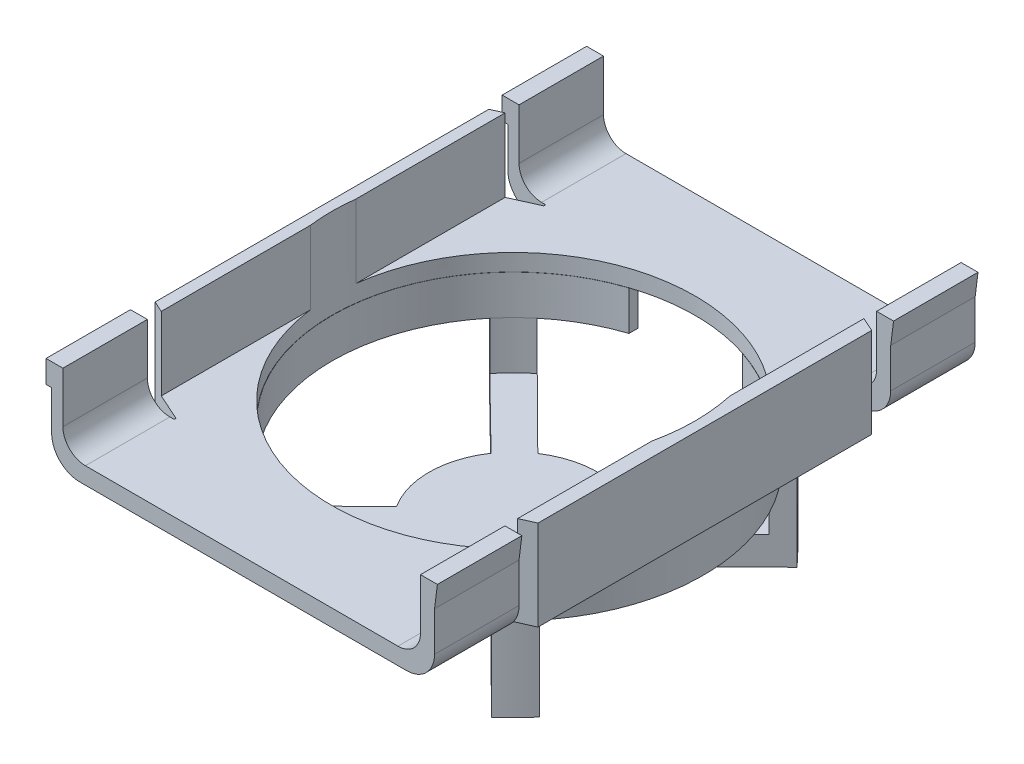
from build123d import *

# Parameters (mm, degrees)
BOSS_EXTRUDE1_DEPTH      = 15
BOSS_EXTRUDE2_DEPTH      = 66
CUT_EXTRUDE1_DEPTH       = 16
FILLET1_R                = 0.2
SKETCH5_R                = 32.25
CUT_EXTRUDE2_DEPTH       = 66
BOSS_EXTRUDE7_DEPTH      = 7
BOSS_EXTRUDE9_DEPTH      = 13.5
BOSS_EXTRUDE9_DEPTH_BACK = 7
BOSS_EXTRUDE10_DEPTH     = 5


with BuildPart() as part:
    # Sketch1 → Boss-Extrude1 (new body)
    with BuildSketch(Plane.XY):
        with BuildLine():
            Line((-35.569135578, 10.252622841), (-35.569135578, 6.252622841))
            Line((-35.569135578, 6.252622841), (-34.569135578, 6.252622841))
            Line((-34.569135578, 6.252622841), (-34.569135578, -0.747377159))
            ThreePointArc((-34.569135578, -0.747377159), (-33.104669484, -4.282911065), (-29.569135578, -5.747377159))
            Line((-29.569135578, -5.747377159), (28.430864422, -5.747377159))
            ThreePointArc((28.430864422, -5.747377159), (31.966398327, -4.282911065), (33.430864422, -0.747377159))
            Line((33.430864422, -0.747377159), (33.430864422, 6.252622841))
            Line((33.430864422, 6.252622841), (33.930864422, 10.252622841))
            Line((33.930864422, 10.252622841), (30.930864422, 10.252622841))
            Line((30.930864422, 10.252622841), (30.930864422, 1.252622841))
            ThreePointArc((30.930864422, 1.252622841), (29.759291546, -1.575804284), (26.930864422, -2.747377159))
            Line((26.930864422, -2.747377159), (-28.569135578, -2.747377159))
            ThreePointArc((-28.569135578, -2.747377159), (-31.397562703, -1.575804284), (-32.569135578, 1.252622841))
            Line((-32.569135578, 1.252622841), (-32.569135578, 10.252622841))
            Line((-32.569135578, 10.252622841), (-35.569135578, 10.252622841))
        make_face()
    boss_extrude1 = extrude(amount=BOSS_EXTRUDE1_DEPTH)

    # Sketch2 → Boss-Extrude2 (add)
    with BuildSketch(Plane.XY.offset(15)):
        Polygon((33.430864422, -5.747377159), (-34.569135578, -5.747377159), (-34.569135578, 10.252622841), (-32.569135578, 10.252622841), (-32.569135578, -2.747377159), (30.930864422, -2.747377159), (30.930864422, 10.252622841), (33.430864422, 10.252622841), align=None)
    extrude(amount=BOSS_EXTRUDE2_DEPTH)

    # Mirror1: Boss-Extrude1 across plane
    add(boss_extrude1.mirror(Plane(origin=(0, 0, 48), x_dir=(1, 0, 0), z_dir=(0, 0, -1))))

    # Sketch4 → Cut-Extrude1 (cut)
    with BuildSketch(Plane.XZ.offset(5.747377159)):
        Polygon((-34.569135578, 15), (-27.069135578, 15), (-34.569135578, 18.37), align=None)
        Polygon((33.430864422, 18.37), (33.430864422, 15), (25.930864422, 15), align=None)
        Polygon((33.430864422, 81), (25.930864422, 81), (33.430864422, 77.63), align=None)
        Polygon((-34.569135578, 77.63), (-34.569135578, 81), (-27.069135578, 81), align=None)
    extrude(amount=-CUT_EXTRUDE1_DEPTH, mode=Mode.SUBTRACT)

    # Fillet1
    fillet1_edges = [part.edges().sort_by_distance(p)[0] for p in [
        (-27.069135578, -4.247377159, 15),
        (25.930864422, -4.247377159, 15),
        (25.930864422, -4.247377159, 81),
        (-27.069135578, -4.247377159, 81),
    ]]
    fillet(fillet1_edges, radius=FILLET1_R)

    # Sketch5 → Cut-Extrude2 (cut)
    with BuildSketch(Plane.XZ.offset(5.747377159)):
        with Locations((-0.569135578, 48)):
            Circle(SKETCH5_R)
    extrude(amount=-CUT_EXTRUDE2_DEPTH, mode=Mode.SUBTRACT)

    # Sketch14 → Boss-Extrude7 (add)
    with BuildSketch(Plane.XZ.offset(5.747377159)):
        with BuildLine():
            Line((-10.647665103, 80.175600928), (-10.647665103, 78.600128297))
            ThreePointArc((-10.647665103, 78.600128297), (-32.786283329, 48), (-10.647665103, 17.399871703))
            Line((-10.647665103, 17.399871703), (-10.647665103, 15.824399072))
            ThreePointArc((-10.647665103, 15.824399072), (-34.286283329, 48), (-10.647665103, 80.175600928))
        make_face()
        with BuildLine():
            Line((9.509393946, 17.399871703), (9.509393946, 15.824399072))
            ThreePointArc((9.509393946, 15.824399072), (33.148012172, 48), (9.509393946, 80.175600928))
            Line((9.509393946, 80.175600928), (9.509393946, 78.600128297))
            ThreePointArc((9.509393946, 78.600128297), (31.648012172, 48), (9.509393946, 17.399871703))
        make_face()
    extrude(amount=BOSS_EXTRUDE7_DEPTH)

    # Sketch15 → Boss-Extrude9 (add, two sides)
    with BuildSketch(Plane.XZ.offset(12.747377159)) as boss_extrude9_sk:
        with BuildLine():
            Line((-28.026086912, 70.843608886), (-25.530250363, 68.367592208))
            ThreePointArc((-25.530250363, 68.367592208), (-23.518464715, 70.610271024), (-21.305976378, 72.655212375))
            Line((-21.305976378, 72.655212375), (-23.798751135, 75.131155606))
            ThreePointArc((-23.798751135, 75.131155606), (-26.002927667, 73.076619857), (-28.026086912, 70.843608886))
        make_face()
        with BuildLine():
            Line((22.660479978, 75.131155606), (20.167705221, 72.655212375))
            ThreePointArc((20.167705221, 72.655212375), (22.380193558, 70.610271024), (24.391979206, 68.367592208))
            Line((24.391979206, 68.367592208), (26.887815755, 70.843608886))
            ThreePointArc((26.887815755, 70.843608886), (24.86465651, 73.076619857), (22.660479978, 75.131155606))
        make_face()
        with BuildLine():
            Line((19.996816858, 23.202063312), (22.492653407, 20.726046634))
            ThreePointArc((22.492653407, 20.726046634), (24.694346544, 22.751809679), (26.718776146, 24.954728963))
            Line((26.718776146, 24.954728963), (24.212854805, 27.414835044))
            ThreePointArc((24.212854805, 27.414835044), (22.202466054, 25.210743262), (19.996816858, 23.202063312))
        make_face()
        with BuildLine():
            Line((-21.135088015, 23.202063312), (-23.630924564, 20.726046634))
            ThreePointArc((-23.630924564, 20.726046634), (-25.832617701, 22.751809679), (-27.857047303, 24.954728963))
            Line((-27.857047303, 24.954728963), (-25.351125962, 27.414835044))
            ThreePointArc((-25.351125962, 27.414835044), (-23.340737211, 25.210743262), (-21.135088015, 23.202063312))
        make_face()
    extrude(amount=BOSS_EXTRUDE9_DEPTH)
    extrude(boss_extrude9_sk.sketch, amount=-BOSS_EXTRUDE9_DEPTH_BACK)

    # Sketch17 → Boss-Extrude10 (add)
    with BuildSketch(Plane.XZ.offset(26.247377159)):
        with BuildLine():
            Line((-8.787404877, 35.45169136), (-23.630924564, 20.726046634))
            ThreePointArc((-23.630924564, 20.726046634), (-25.832617701, 22.751809679), (-27.857047303, 24.954728963))
            Line((-27.857047303, 24.954728963), (-12.973551792, 39.566112498))
            ThreePointArc((-12.973551792, 39.566112498), (-15.567939739, 47.810596324), (-13.182567225, 56.11796416))
            Line((-13.182567225, 56.11796416), (-28.026086912, 70.843608886))
            ThreePointArc((-28.026086912, 70.843608886), (-26.002927667, 73.076619857), (-23.798751135, 75.131155606))
            Line((-23.798751135, 75.131155606), (-8.98453465, 60.416966557))
            ThreePointArc((-8.98453465, 60.416966557), (-0.569135578, 63), (7.846263493, 60.416966557))
            Line((7.846263493, 60.416966557), (22.660479978, 75.131155606))
            ThreePointArc((22.660479978, 75.131155606), (24.86465651, 73.076619857), (26.887815755, 70.843608886))
            Line((26.887815755, 70.843608886), (12.044296068, 56.11796416))
            ThreePointArc((12.044296068, 56.11796416), (14.429668582, 47.810596325), (11.835280635, 39.566112498))
            Line((11.835280635, 39.566112498), (26.718776146, 24.954728963))
            ThreePointArc((26.718776146, 24.954728963), (24.694346544, 22.751809679), (22.492653407, 20.726046634))
            Line((22.492653407, 20.726046634), (7.64913372, 35.45169136))
            ThreePointArc((7.64913372, 35.45169136), (-0.569135578, 33), (-8.787404877, 35.45169136))
        make_face()
    extrude(amount=-BOSS_EXTRUDE10_DEPTH)


solid = part.part
